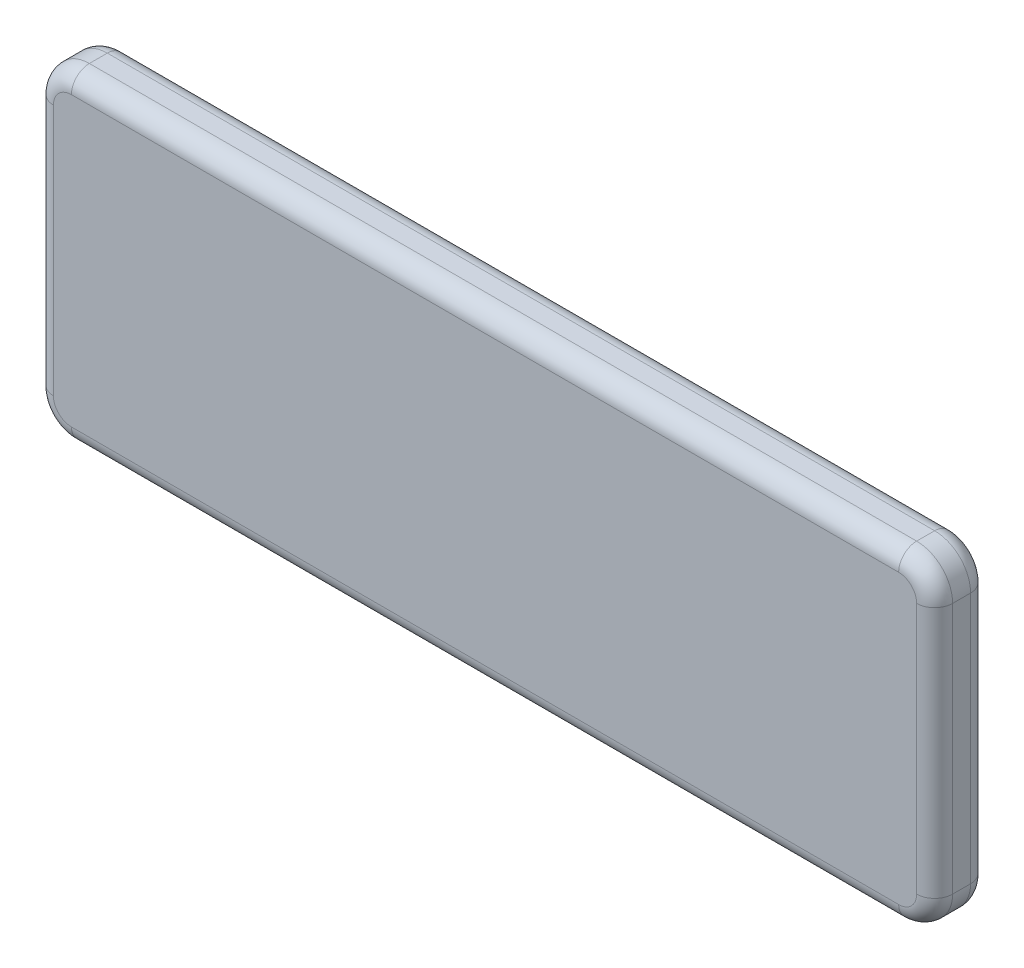
from build123d import *

# Parameters (mm, degrees)
SKETCH1_W           = 250
SKETCH1_H           = 90
BOSS_EXTRUDE1_DEPTH = 15
FILLET1_R           = 10
FILLET2_R           = 5


with BuildPart() as part:
    # Sketch1 → Boss-Extrude1 (new body)
    with BuildSketch(Plane.XY):
        Rectangle(SKETCH1_W, SKETCH1_H)
    extrude(amount=BOSS_EXTRUDE1_DEPTH)

    # Fillet1
    fillet1_edges = [part.edges().sort_by_distance(p)[0] for p in [
        (125, -45, 7.5),
        (-125, -45, 7.5),
        (-125, 45, 7.5),
        (125, 45, 7.5),
    ]]
    fillet(fillet1_edges, radius=FILLET1_R)

    # Fillet2
    fillet2_edges = [part.edges().sort_by_distance(p)[0] for p in [
        (0, 45, 0),
        (0, 45, 15),
        (125, 0, 0),
        (0, -45, 0),
        (-125, 0, 0),
        (-122.071067812, 42.071067812, 0),
        (-122.071067812, -42.071067812, 0),
        (122.071067812, -42.071067812, 0),
        (122.071067812, 42.071067812, 0),
        (125, 0, 15),
        (-125, 0, 15),
        (0, -45, 15),
        (-122.071067812, 42.071067812, 15),
        (-122.071067812, -42.071067812, 15),
        (122.071067812, -42.071067812, 15),
        (122.071067812, 42.071067812, 15),
    ]]
    fillet(fillet2_edges, radius=FILLET2_R)


solid = part.part
